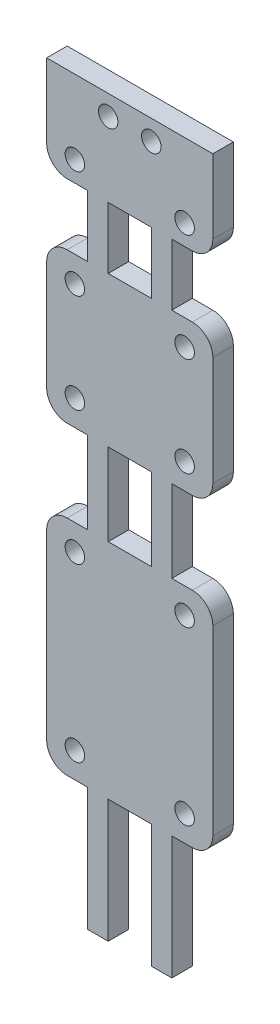
from build123d import *

# Parameters (mm, degrees)
SKETCH1_R           = 0.95
SKETCH1_W           = 4.2
SKETCH1_H           = 6
SKETCH1_H_2         = 8
BOSS_EXTRUDE1_DEPTH = 2


with BuildPart() as part:
    # Sketch1 → Boss-Extrude1 (new body)
    with BuildSketch(Plane.XY):
        with BuildLine():
            Line((2, 47.74), (4, 47.74))
            Line((4, 47.74), (4, 55.74))
            Line((4, 55.74), (2, 55.74))
            ThreePointArc((2, 55.74), (0.585786438, 56.325786438), (0, 57.74))
            Line((0, 57.74), (0, 68.385))
            ThreePointArc((0, 68.385), (0.585786438, 69.799213562), (2, 70.385))
            Line((2, 70.385), (4, 70.385))
            Line((4, 70.385), (4, 76.385))
            Line((4, 76.385), (2, 76.385))
            ThreePointArc((2, 76.385), (0.585786438, 76.970786438), (0, 78.385))
            Line((0, 78.385), (0, 85.59))
            Line((0, 85.59), (16.2, 85.59))
            Line((16.2, 85.59), (16.2, 78.385))
            ThreePointArc((16.2, 78.385), (15.614213562, 76.970786438), (14.2, 76.385))
            Line((14.2, 76.385), (12.2, 76.385))
            Line((12.2, 76.385), (12.2, 70.385))
            Line((12.2, 70.385), (14.2, 70.385))
            ThreePointArc((14.2, 70.385), (15.614213562, 69.799213562), (16.2, 68.385))
            Line((16.2, 68.385), (16.2, 57.74))
            ThreePointArc((16.2, 57.74), (15.614213562, 56.325786438), (14.2, 55.74))
            Line((14.2, 55.74), (12.2, 55.74))
            Line((12.2, 55.74), (12.2, 47.74))
            Line((12.2, 47.74), (14.2, 47.74))
            ThreePointArc((14.2, 47.74), (15.614213562, 47.154213562), (16.2, 45.74))
            Line((16.2, 45.74), (16.2, 28))
            ThreePointArc((16.2, 28), (15.614213562, 26.585786438), (14.2, 26))
            Line((14.2, 26), (12.2, 26))
            Line((12.2, 26), (12.2, 14))
            Line((12.2, 14), (10.2, 14))
            Line((10.2, 14), (10.2, 26))
            Line((10.2, 26), (6, 26))
            Line((6, 26), (6, 14))
            Line((6, 14), (4, 14))
            Line((4, 14), (4, 26))
            Line((4, 26), (2, 26))
            ThreePointArc((2, 26), (0.585786438, 26.585786438), (0, 28))
            Line((0, 28), (0, 45.74))
            ThreePointArc((0, 45.74), (0.585786438, 47.154213562), (2, 47.74))
        make_face()
        with Locations((13.45, 45.24)):
            Circle(SKETCH1_R, mode=Mode.SUBTRACT)
        with Locations((2.75, 67.885)):
            Circle(SKETCH1_R, mode=Mode.SUBTRACT)
        with Locations((13.45, 58.24)):
            Circle(SKETCH1_R, mode=Mode.SUBTRACT)
        with Locations((13.45, 78.385)):
            Circle(SKETCH1_R, mode=Mode.SUBTRACT)
        with Locations((2.75, 28.5)):
            Circle(SKETCH1_R, mode=Mode.SUBTRACT)
        with Locations((2.75, 78.385)):
            Circle(SKETCH1_R, mode=Mode.SUBTRACT)
        with Locations((2.75, 58.24)):
            Circle(SKETCH1_R, mode=Mode.SUBTRACT)
        with Locations((6, 83.635)):
            Circle(SKETCH1_R, mode=Mode.SUBTRACT)
        with Locations((13.45, 28.5)):
            Circle(SKETCH1_R, mode=Mode.SUBTRACT)
        with Locations((13.45, 67.885)):
            Circle(SKETCH1_R, mode=Mode.SUBTRACT)
        with Locations((10.2, 83.635)):
            Circle(SKETCH1_R, mode=Mode.SUBTRACT)
        with Locations((2.75, 45.24)):
            Circle(SKETCH1_R, mode=Mode.SUBTRACT)
        with Locations((8.1, 73.385)):
            Rectangle(SKETCH1_W, SKETCH1_H, mode=Mode.SUBTRACT)
        with Locations((8.1, 51.74)):
            Rectangle(SKETCH1_W, SKETCH1_H_2, mode=Mode.SUBTRACT)
    extrude(amount=BOSS_EXTRUDE1_DEPTH)


solid = part.part
